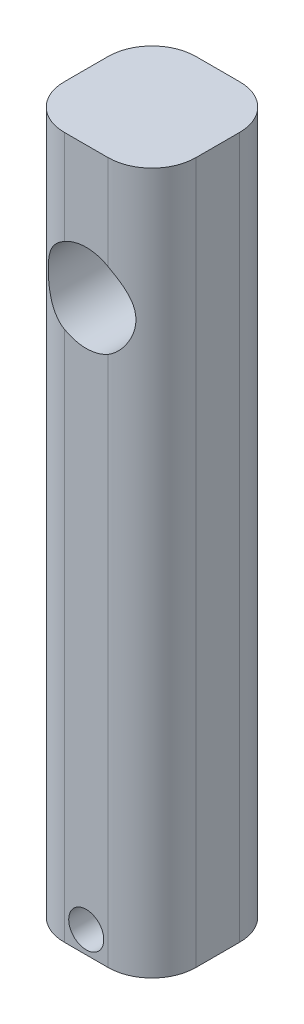
from build123d import *

# Parameters (mm, degrees)
BOSS_EXTRUDE2_DEPTH     = 203.2
SKETCH4_R               = 12.7
SKETCH4_R_2             = 5.08
CUT_EXTRUDE1_DEPTH      = 76.2
CUT_EXTRUDE1_DEPTH_BACK = 92.964


with BuildPart() as part:
    # Sketch1 → Boss-Extrude2 (new body)
    with BuildSketch(Plane(origin=(0, 0, 0), x_dir=(1, 0, 0), z_dir=(0, 1, 0))):
        with BuildLine():
            Line((-6.35, -19.05), (6.35, -19.05))
            ThreePointArc((6.35, -19.05), (15.330256121, -15.330256121), (19.05, -6.35))
            Line((19.05, -6.35), (19.05, 6.35))
            ThreePointArc((19.05, 6.35), (15.330256121, 15.330256121), (6.35, 19.05))
            Line((6.35, 19.05), (-6.35, 19.05))
            ThreePointArc((-6.35, 19.05), (-15.330256121, 15.330256121), (-19.05, 6.35))
            Line((-19.05, 6.35), (-19.05, -6.35))
            ThreePointArc((-19.05, -6.35), (-15.330256121, -15.330256121), (-6.35, -19.05))
        make_face()
    extrude(amount=BOSS_EXTRUDE2_DEPTH)

    # Sketch4 → Cut-Extrude1 (cut, two sides)
    with BuildSketch(Plane.XY) as cut_extrude1_sk:
        with Locations((0, 164.846)):
            Circle(SKETCH4_R)
        with Locations((0, 6.35)):
            Circle(SKETCH4_R_2)
    extrude(amount=CUT_EXTRUDE1_DEPTH, mode=Mode.SUBTRACT)
    extrude(cut_extrude1_sk.sketch, amount=-CUT_EXTRUDE1_DEPTH_BACK, mode=Mode.SUBTRACT)


solid = part.part
